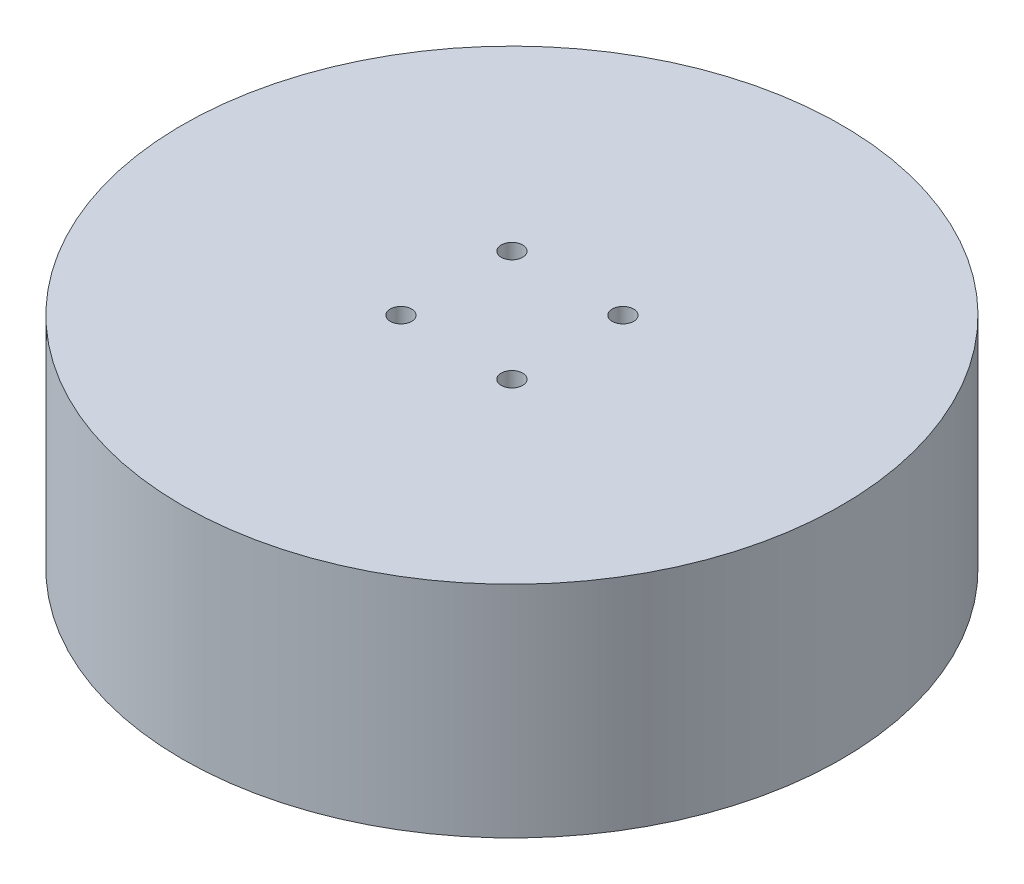
from build123d import *

# Parameters (mm, degrees)
SKETCH1_R                          = 31.5
BOSS_EXTRUDE1_DEPTH                = 21
TAP_DRILL_FOR_M2_5X0_45_TAP2_D     = 2.05
TAP_DRILL_FOR_M2_5X0_45_TAP2_DEPTH = 7
TAP_DRILL_FOR_M2_5X0_45_TAP2_TIP   = 0.615882135
SKETCH6_R                          = 27
CUT_EXTRUDE1_DEPTH                 = 10


with BuildPart() as part:
    # Sketch1 → Boss-Extrude1 (new body)
    with BuildSketch(Plane(origin=(0, 0, 0), x_dir=(1, 0, 0), z_dir=(0, 1, 0))):
        Circle(SKETCH1_R)
    extrude(amount=BOSS_EXTRUDE1_DEPTH)

    # Tap Drill for M2.5x0.45 Tap2
    with Locations(Plane(origin=(0, 21, 0), x_dir=(1, 0, 0), z_dir=(0, 1, 0))):
        with Locations((-5.303300859, 5.303300859), (5.303300859, 5.303300859), (5.303300859, -5.303300859), (-5.303300859, -5.303300859)):
            Hole(TAP_DRILL_FOR_M2_5X0_45_TAP2_D / 2, depth=TAP_DRILL_FOR_M2_5X0_45_TAP2_DEPTH)
            with Locations((0, 0, -(TAP_DRILL_FOR_M2_5X0_45_TAP2_DEPTH + TAP_DRILL_FOR_M2_5X0_45_TAP2_TIP / 2))):  # 118° drill point
                Cone(0, TAP_DRILL_FOR_M2_5X0_45_TAP2_D / 2, TAP_DRILL_FOR_M2_5X0_45_TAP2_TIP, mode=Mode.SUBTRACT)

    # Sketch6 → Cut-Extrude1 (cut)
    with BuildSketch(Plane.XZ):
        Circle(SKETCH6_R)
    extrude(amount=-CUT_EXTRUDE1_DEPTH, mode=Mode.SUBTRACT)


solid = part.part
